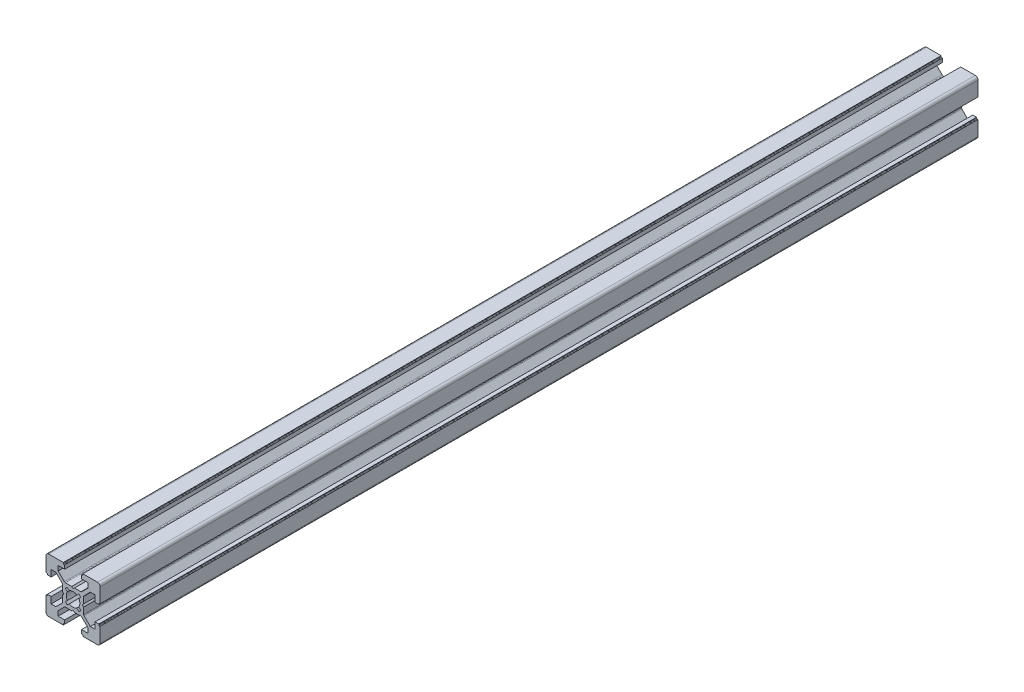
from build123d import *

# Parameters (mm, degrees)
EXTRUDE1_DEPTH = 324


with BuildPart() as part:
    # Sketch1 → Extrude1 (new body)
    with BuildSketch(Plane.XY):
        with BuildLine():
            Line((0, 3.4), (-0.5, 3.9))
            Line((-0.5, 3.9), (-2.844365081, 3.9))
            ThreePointArc((-2.844365081, 3.9), (-3.035706798, 3.938060234), (-3.197918472, 4.046446609))
            Line((-3.197918472, 4.046446609), (-5.5, 6.348528137))
            Line((-5.5, 6.348528137), (-5.5, 8.1))
            Line((-5.5, 8.1), (-3.1, 8.1))
            Line((-3.1, 8.1), (-3.1, 9.5))
            Line((-3.1, 9.5), (-3.4, 9.5))
            ThreePointArc((-3.4, 9.5), (-3.541421356, 9.558578644), (-3.6, 9.7))
            Line((-3.6, 9.7), (-3.6, 10))
            Line((-3.6, 10), (-9, 10))
            ThreePointArc((-9, 10), (-9.707106781, 9.707106781), (-10, 9))
            Line((-10, 9), (-10, 3.6))
            Line((-10, 3.6), (-9.7, 3.6))
            ThreePointArc((-9.7, 3.6), (-9.558578644, 3.541421356), (-9.5, 3.4))
            Line((-9.5, 3.4), (-9.5, 3.1))
            Line((-9.5, 3.1), (-8.1, 3.1))
            Line((-8.1, 3.1), (-8.1, 5.5))
            Line((-8.1, 5.5), (-6.348528137, 5.5))
            Line((-6.348528137, 5.5), (-4.046446609, 3.197918472))
            ThreePointArc((-4.046446609, 3.197918472), (-3.938060234, 3.035706798), (-3.9, 2.844365081))
            Line((-3.9, 2.844365081), (-3.9, 0.5))
            Line((-3.9, 0.5), (-3.4, 0))
            Line((-3.4, 0), (-3.9, -0.5))
            Line((-3.9, -0.5), (-3.9, -2.844365081))
            ThreePointArc((-3.9, -2.844365081), (-3.938060234, -3.035706798), (-4.046446609, -3.197918472))
            Line((-4.046446609, -3.197918472), (-6.348528137, -5.5))
            Line((-6.348528137, -5.5), (-8.1, -5.5))
            Line((-8.1, -5.5), (-8.1, -3.1))
            Line((-8.1, -3.1), (-9.5, -3.1))
            Line((-9.5, -3.1), (-9.5, -3.4))
            ThreePointArc((-9.5, -3.4), (-9.558578644, -3.541421356), (-9.7, -3.6))
            Line((-9.7, -3.6), (-10, -3.6))
            Line((-10, -3.6), (-10, -9))
            ThreePointArc((-10, -9), (-9.707106781, -9.707106781), (-9, -10))
            Line((-9, -10), (-3.6, -10))
            Line((-3.6, -10), (-3.6, -9.7))
            ThreePointArc((-3.6, -9.7), (-3.541421356, -9.558578644), (-3.4, -9.5))
            Line((-3.4, -9.5), (-3.1, -9.5))
            Line((-3.1, -9.5), (-3.1, -8.1))
            Line((-3.1, -8.1), (-5.5, -8.1))
            Line((-5.5, -8.1), (-5.5, -6.348528137))
            Line((-5.5, -6.348528137), (-3.197918472, -4.046446609))
            ThreePointArc((-3.197918472, -4.046446609), (-3.035706798, -3.938060234), (-2.844365081, -3.9))
            Line((-2.844365081, -3.9), (-0.5, -3.9))
            Line((-0.5, -3.9), (0, -3.4))
            Line((0, -3.4), (0.5, -3.9))
            Line((0.5, -3.9), (2.844365081, -3.9))
            ThreePointArc((2.844365081, -3.9), (3.035706798, -3.938060234), (3.197918472, -4.046446609))
            Line((3.197918472, -4.046446609), (5.5, -6.348528137))
            Line((5.5, -6.348528137), (5.5, -8.1))
            Line((5.5, -8.1), (3.1, -8.1))
            Line((3.1, -8.1), (3.1, -9.5))
            Line((3.1, -9.5), (3.4, -9.5))
            ThreePointArc((3.4, -9.5), (3.541421356, -9.558578644), (3.6, -9.7))
            Line((3.6, -9.7), (3.6, -10))
            Line((3.6, -10), (9, -10))
            ThreePointArc((9, -10), (9.707106781, -9.707106781), (10, -9))
            Line((10, -9), (10, -3.6))
            Line((10, -3.6), (9.7, -3.6))
            ThreePointArc((9.7, -3.6), (9.558578644, -3.541421356), (9.5, -3.4))
            Line((9.5, -3.4), (9.5, -3.1))
            Line((9.5, -3.1), (8.1, -3.1))
            Line((8.1, -3.1), (8.1, -5.5))
            Line((8.1, -5.5), (6.348528137, -5.5))
            Line((6.348528137, -5.5), (4.046446609, -3.197918472))
            ThreePointArc((4.046446609, -3.197918472), (3.938060234, -3.035706798), (3.9, -2.844365081))
            Line((3.9, -2.844365081), (3.9, -0.5))
            Line((3.9, -0.5), (3.4, 0))
            Line((3.4, 0), (3.9, 0.5))
            Line((3.9, 0.5), (3.9, 2.844365081))
            ThreePointArc((3.9, 2.844365081), (3.938060234, 3.035706798), (4.046446609, 3.197918472))
            Line((4.046446609, 3.197918472), (6.348528137, 5.5))
            Line((6.348528137, 5.5), (8.1, 5.5))
            Line((8.1, 5.5), (8.1, 3.1))
            Line((8.1, 3.1), (9.5, 3.1))
            Line((9.5, 3.1), (9.5, 3.4))
            ThreePointArc((9.5, 3.4), (9.558578644, 3.541421356), (9.7, 3.6))
            Line((9.7, 3.6), (10, 3.6))
            Line((10, 3.6), (10, 9))
            ThreePointArc((10, 9), (9.707106781, 9.707106781), (9, 10))
            Line((9, 10), (3.6, 10))
            Line((3.6, 10), (3.6, 9.7))
            ThreePointArc((3.6, 9.7), (3.541421356, 9.558578644), (3.4, 9.5))
            Line((3.4, 9.5), (3.1, 9.5))
            Line((3.1, 9.5), (3.1, 8.1))
            Line((3.1, 8.1), (5.5, 8.1))
            Line((5.5, 8.1), (5.5, 6.348528137))
            Line((5.5, 6.348528137), (3.197918472, 4.046446609))
            ThreePointArc((3.197918472, 4.046446609), (3.035706798, 3.938060234), (2.844365081, 3.9))
            Line((2.844365081, 3.9), (0.5, 3.9))
            Line((0.5, 3.9), (0, 3.4))
        make_face()
        with BuildLine():
            ThreePointArc((2.5, 0), (2.394160656, -0.719718523), (2.085604198, -1.378497417))
            Line((2.085604198, -1.378497417), (2.828427125, -2.121320344))
            Line((2.828427125, -2.121320344), (2.121320344, -2.828427125))
            Line((2.121320344, -2.828427125), (1.378497417, -2.085604198))
            ThreePointArc((1.378497417, -2.085604198), (0, -2.5), (-1.378497417, -2.085604198))
            Line((-1.378497417, -2.085604198), (-2.121320344, -2.828427125))
            Line((-2.121320344, -2.828427125), (-2.828427125, -2.121320344))
            Line((-2.828427125, -2.121320344), (-2.085604198, -1.378497417))
            ThreePointArc((-2.085604198, -1.378497417), (-2.5, 0), (-2.085604198, 1.378497417))
            Line((-2.085604198, 1.378497417), (-2.828427125, 2.121320344))
            Line((-2.828427125, 2.121320344), (-2.121320344, 2.828427125))
            Line((-2.121320344, 2.828427125), (-1.378497417, 2.085604198))
            ThreePointArc((-1.378497417, 2.085604198), (0, 2.5), (1.378497417, 2.085604198))
            Line((1.378497417, 2.085604198), (2.121320344, 2.828427125))
            Line((2.121320344, 2.828427125), (2.828427125, 2.121320344))
            Line((2.828427125, 2.121320344), (2.085604198, 1.378497417))
            ThreePointArc((2.085604198, 1.378497417), (2.394160656, 0.719718523), (2.5, 0))
        make_face(mode=Mode.SUBTRACT)
    extrude(amount=EXTRUDE1_DEPTH)


solid = part.part
